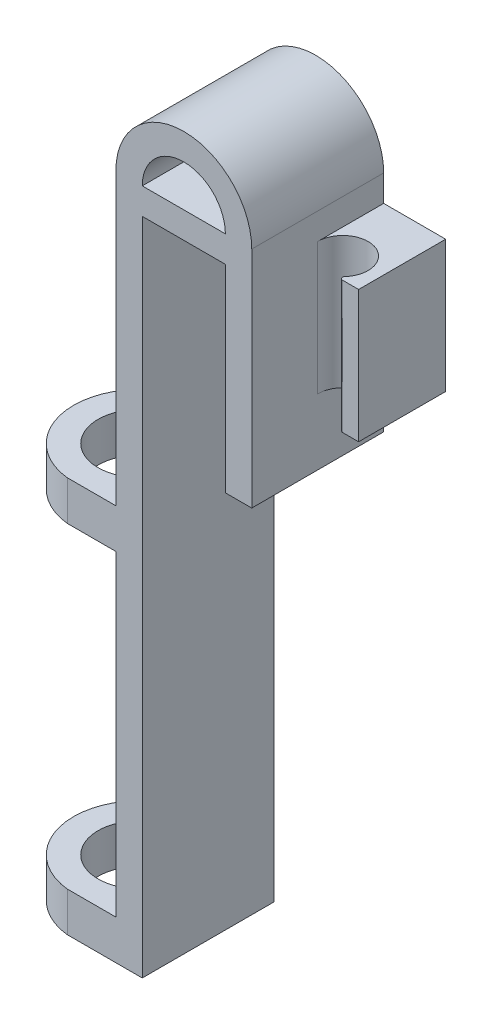
from build123d import *

# Parameters (mm, degrees)
SKETCH1_W           = 2
SKETCH1_H           = 50
SKETCH1_H_2         = 15
BOSS_EXTRUDE1_DEPTH = 10
SKETCH2_W           = 8.2
SKETCH2_H           = 3
BOSS_EXTRUDE2_DEPTH = 10
SKETCH3_R           = 3.175
CUT_EXTRUDE1_DEPTH  = 30
CUT_EXTRUDE2_DEPTH  = 30
BOSS_EXTRUDE3_DEPTH = 10
SKETCH6_W           = 4.7
SKETCH6_H           = 10
BOSS_EXTRUDE4_DEPTH = 10
SKETCH7_R           = 1.91
CUT_EXTRUDE3_DEPTH  = 10
CUT_EXTRUDE4_DEPTH  = 10
FILLET1_R           = 0.2


with BuildPart() as part:
    # Sketch1 → Boss-Extrude1 (new body)
    with BuildSketch(Plane.XY):
        with Locations((-1, -25)):
            Rectangle(SKETCH1_W, SKETCH1_H)
        Polygon((-2, 0), (0, 0), (6.3, 0), (8.3, 0), (8.3, 2), (-2, 2), align=None)
        with Locations((7.3, -7.5)):
            Rectangle(SKETCH1_W, SKETCH1_H_2)
    extrude(amount=BOSS_EXTRUDE1_DEPTH)

    # Sketch2 → Boss-Extrude2 (add)
    with BuildSketch(Plane.XY.offset(10)):
        with Locations((-6.1, -48.5)):
            Rectangle(SKETCH2_W, SKETCH2_H)
        with Locations((-6.1, -21.5)):
            Rectangle(SKETCH2_W, SKETCH2_H)
    extrude(amount=-BOSS_EXTRUDE2_DEPTH)

    # Sketch3 → Cut-Extrude1 (cut)
    with BuildSketch(Plane(origin=(0, -20, 0), x_dir=(1, 0, 0), z_dir=(0, 1, 0))):
        with Locations((-5.175, -5)):
            Circle(SKETCH3_R)
    extrude(amount=-CUT_EXTRUDE1_DEPTH, mode=Mode.SUBTRACT)

    # Sketch4 → Cut-Extrude2 (cut)
    with BuildSketch(Plane(origin=(0, -20, 0), x_dir=(1, 0, 0), z_dir=(0, 1, 0))):
        with BuildLine():
            Line((-5.67562461, 0), (-10.2, 0))
            Line((-10.2, 0), (-10.2, -5))
            ThreePointArc((-10.2, -5), (-8.901007492, -1.62842868), (-5.67562461, 0))
        make_face()
        with BuildLine():
            ThreePointArc((-5.67562461, -10), (-8.901007492, -8.37157132), (-10.2, -5))
            Line((-10.2, -5), (-10.2, -10))
            Line((-10.2, -10), (-5.67562461, -10))
        make_face()
    extrude(amount=-CUT_EXTRUDE2_DEPTH, mode=Mode.SUBTRACT)

    # Sketch5 → Boss-Extrude3 (add)
    with BuildSketch(Plane.XY.offset(10)):
        with BuildLine():
            Line((-2, 2), (0, 2))
            ThreePointArc((0, 2), (3.15, 5.15), (6.3, 2))
            Line((6.3, 2), (8.3, 2))
            ThreePointArc((8.3, 2), (3.15, 7.15), (-2, 2))
        make_face()
    extrude(amount=-BOSS_EXTRUDE3_DEPTH)

    # Sketch6 → Boss-Extrude4 (add)
    with BuildSketch(Plane.XY.offset(10)):
        with Locations((10.65, -5)):
            Rectangle(SKETCH6_W, SKETCH6_H)
    extrude(amount=-BOSS_EXTRUDE4_DEPTH)

    # Sketch7 → Cut-Extrude3 (cut)
    with BuildSketch(Plane(origin=(0, 0, 0), x_dir=(1, 0, 0), z_dir=(0, 1, 0))):
        with Locations((10.21, -5)):
            Circle(SKETCH7_R)
    extrude(amount=-CUT_EXTRUDE3_DEPTH, mode=Mode.SUBTRACT)

    # Sketch8 → Cut-Extrude4 (cut)
    with BuildSketch(Plane(origin=(0, 0, 0), x_dir=(1, 0, 0), z_dir=(0, 1, 0))):
        with BuildLine():
            Line((13, -6.6), (13, -10))
            Line((13, -10), (8.3, -10))
            Line((8.3, -10), (8.3, -5))
            ThreePointArc((8.3, -5), (9.30012633, -6.679354014), (11.253120319, -6.6))
            Line((11.253120319, -6.6), (13, -6.6))
        make_face()
    extrude(amount=-CUT_EXTRUDE4_DEPTH, mode=Mode.SUBTRACT)

    # Fillet1
    fillet1_edges = [part.edges().sort_by_distance(p)[0] for p in [
        (11.253120319, -5, 6.6),
    ]]
    fillet(fillet1_edges, radius=FILLET1_R)


solid = part.part
